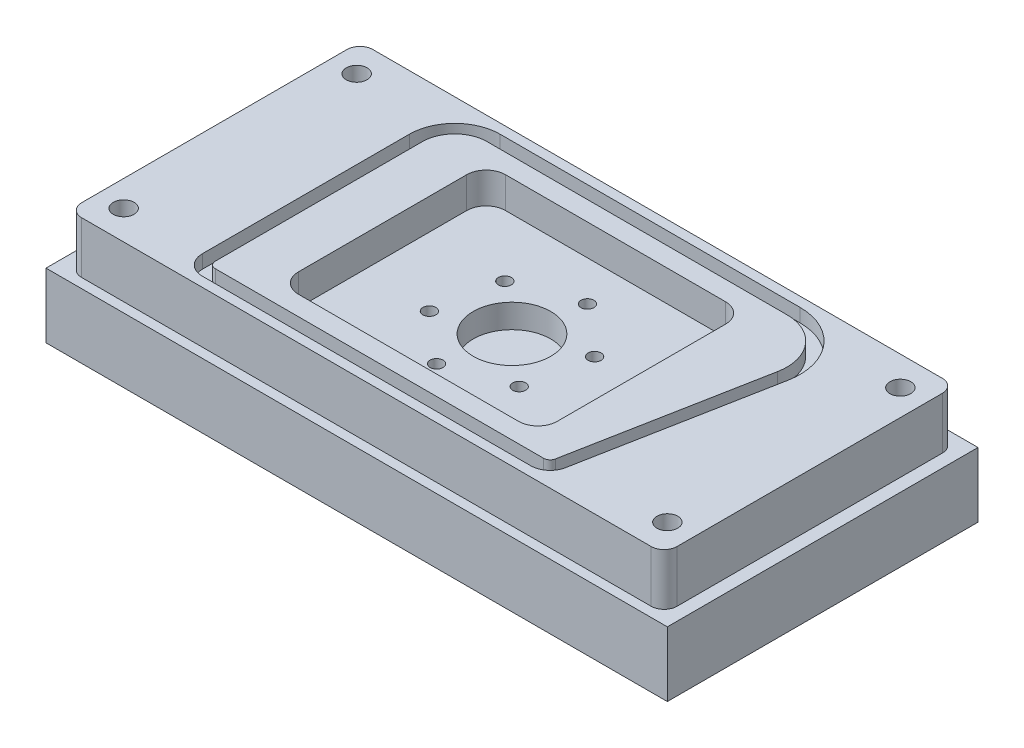
from build123d import *

# Parameters (mm, degrees)
SKETCH1_W                      = 152.4
SKETCH1_H                      = 76.2
BOSS_EXTRUDE1_DEPTH            = 28.575
SKETCH2_R                      = 9.525
CUT_EXTRUDE1_DEPTH             = 13.462
CUT_EXTRUDE3_DEPTH             = 3.302
CUT_EXTRUDE4_DEPTH             = 7.62
F_7_0_201_DIAMETER_HOLE1_D     = 5.1054
F_7_0_201_DIAMETER_HOLE1_DEPTH = 14.2748
F_7_0_201_DIAMETER_HOLE1_TIP   = 1.533816902
SKETCH10_OUTSIDE_W             = 188.954
SKETCH10_OUTSIDE_H             = 112.754
CUT_EXTRUDE5_DEPTH             = 12.7
CIRPATTERN1_COUNT              = 6


with BuildPart() as part:
    # Sketch1 → Boss-Extrude1 (new body)
    with BuildSketch(Plane(origin=(0, 0, 0), x_dir=(1, 0, 0), z_dir=(0, 1, 0))):
        Rectangle(SKETCH1_W, SKETCH1_H)
    extrude(amount=BOSS_EXTRUDE1_DEPTH)

    # Sketch2 → Cut-Extrude1 (cut)
    with BuildSketch(Plane(origin=(0, 28.575, 0), x_dir=(1, 0, 0), z_dir=(0, 1, 0))):
        Circle(SKETCH2_R)
    extrude(amount=-CUT_EXTRUDE1_DEPTH, mode=Mode.SUBTRACT)

    # Sketch4 → Cut-Extrude3 (cut)
    with BuildSketch(Plane(origin=(0, 28.575, 0), x_dir=(1, 0, 0), z_dir=(0, 1, 0))):
        with BuildLine():
            Line((-36.2712, 33.3375), (37.288597325, 33.3375))
            ThreePointArc((37.288597325, 33.3375), (48.293963964, 28.161232705), (51.324986679, 16.383086023))
            Line((51.324986679, 16.383086023), (42.614045782, -29.463971326))
            ThreePointArc((42.614045782, -29.463971326), (40.9723269, -32.243455546), (37.935249331, -33.3375))
            Line((37.935249331, -33.3375), (-42.6212, -33.3375))
            ThreePointArc((-42.6212, -33.3375), (-45.988796045, -31.942596045), (-47.3837, -28.575))
            Line((-47.3837, -28.575), (-47.3837, 22.225))
            ThreePointArc((-47.3837, 22.225), (-44.128924106, 30.082724106), (-36.2712, 33.3375))
        make_face()
        with BuildLine():
            ThreePointArc((-36.2712, 30.1625), (-41.883860076, 27.837660076), (-44.2087, 22.225))
            Line((-44.2087, 22.225), (-44.2087, -28.575))
            ThreePointArc((-44.2087, -28.575), (-43.743732015, -29.697532015), (-42.6212, -30.1625))
            Line((-42.6212, -30.1625), (37.935249331, -30.1625))
            ThreePointArc((37.935249331, -30.1625), (38.947608521, -29.797818515), (39.494848148, -28.871323775))
            Line((39.494848148, -28.871323775), (48.205789045, 16.975733573))
            ThreePointArc((48.205789045, 16.975733573), (45.848326933, 26.136514326), (37.288597325, 30.1625))
            Line((37.288597325, 30.1625), (-36.2712, 30.1625))
        make_face(mode=Mode.SUBTRACT)
    extrude(amount=-CUT_EXTRUDE3_DEPTH, mode=Mode.SUBTRACT)

    # Sketch7 → Cut-Extrude4 (cut)
    with BuildSketch(Plane(origin=(0, 28.575, 0), x_dir=(1, 0, 0), z_dir=(0, 1, 0))):
        with BuildLine():
            Line((31.75, 20.6375), (31.75, -20.6375))
            ThreePointArc((31.75, -20.6375), (30.355096045, -24.005096045), (26.9875, -25.4))
            Line((26.9875, -25.4), (-26.9875, -25.4))
            ThreePointArc((-26.9875, -25.4), (-30.355096045, -24.005096045), (-31.75, -20.6375))
            Line((-31.75, -20.6375), (-31.75, 20.6375))
            ThreePointArc((-31.75, 20.6375), (-30.355096045, 24.005096045), (-26.9875, 25.4))
            Line((-26.9875, 25.4), (26.9875, 25.4))
            ThreePointArc((26.9875, 25.4), (30.355096045, 24.005096045), (31.75, 20.6375))
        make_face()
    extrude(amount=-CUT_EXTRUDE4_DEPTH, mode=Mode.SUBTRACT)

    # #7 (0.201) Diameter Hole1
    with Locations(Plane(origin=(0, 28.575, 0), x_dir=(-1, 0, 0), z_dir=(0, 1, 0))):
        with Locations((66.675, -28.575), (-66.675, -28.575), (-66.675, 28.575), (66.675, 28.575)):
            Hole(F_7_0_201_DIAMETER_HOLE1_D / 2, depth=F_7_0_201_DIAMETER_HOLE1_DEPTH)
            with Locations((0, 0, -(F_7_0_201_DIAMETER_HOLE1_DEPTH + F_7_0_201_DIAMETER_HOLE1_TIP / 2))):  # 118° drill point
                Cone(0, F_7_0_201_DIAMETER_HOLE1_D / 2, F_7_0_201_DIAMETER_HOLE1_TIP, mode=Mode.SUBTRACT)

    # Sketch10 outside → Cut-Extrude5 (cut)
    with BuildSketch(Plane(origin=(0, 28.575, 0), x_dir=(1, 0, 0), z_dir=(0, 1, 0))):
        Rectangle(SKETCH10_OUTSIDE_W, SKETCH10_OUTSIDE_H)
        with BuildLine():
            Line((-73.025, 32.54502), (-73.025, -32.54502))
            ThreePointArc((-73.025, -32.54502), (-72.09506403, -34.79008403), (-69.85, -35.72002))
            Line((-69.85, -35.72002), (69.85, -35.72002))
            ThreePointArc((69.85, -35.72002), (72.09506403, -34.79008403), (73.025, -32.54502))
            Line((73.025, -32.54502), (73.025, 32.54502))
            ThreePointArc((73.025, 32.54502), (72.09506403, 34.79008403), (69.85, 35.72002))
            Line((69.85, 35.72002), (-69.85, 35.72002))
            ThreePointArc((-69.85, 35.72002), (-72.09506403, 34.79008403), (-73.025, 32.54502))
        make_face(mode=Mode.SUBTRACT)
    extrude(amount=-CUT_EXTRUDE5_DEPTH, mode=Mode.SUBTRACT)

    # Sketch13 → 1/8 (0.125) Diameter Hole1 (revolve, cut)
    with BuildSketch(Plane(origin=(14.964433671, 20.955, -5.29918389), x_dir=(0, 0, 1), z_dir=(1, 0, 0))):
        Polygon((0, 0), (0, 18.429066233), (1.5875, 17.4752), (1.5875, 0), align=None)
    f_1_8_0_125_diameter_hole1 = revolve(axis=Axis((14.964433671, 27.305, -5.29918389), (0, -1, 0)), mode=Mode.SUBTRACT)

    # CirPattern1: 1/8 (0.125) Diameter Hole1 ×6 about axis
    cirpattern1_axis = Axis((0, 0, 0), (0, 1, 0))
    for i in range(1, CIRPATTERN1_COUNT):
        add(f_1_8_0_125_diameter_hole1.rotate(cirpattern1_axis, i * 360 / CIRPATTERN1_COUNT), mode=Mode.SUBTRACT)


solid = part.part
